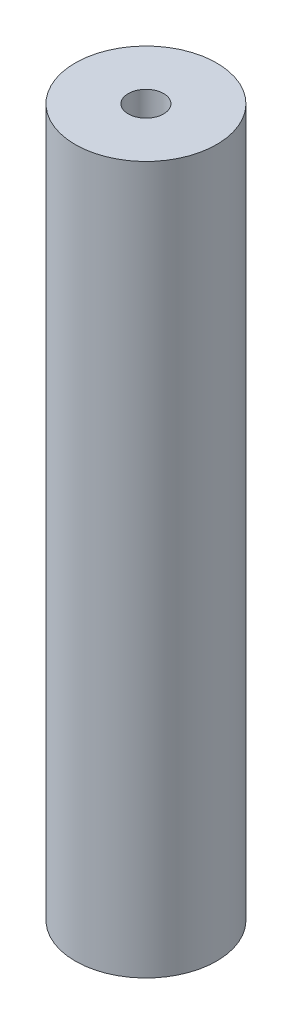
from build123d import *

# Parameters (mm, degrees)
SKETCH1_R           = 100
BOSS_EXTRUDE1_DEPTH = 1000
SKETCH2_R           = 25
CUT_EXTRUDE1_DEPTH  = 50


with BuildPart() as part:
    # Sketch1 → Boss-Extrude1 (new body)
    with BuildSketch(Plane(origin=(0, 0, 0), x_dir=(1, 0, 0), z_dir=(0, 1, 0))):
        Circle(SKETCH1_R)
    extrude(amount=BOSS_EXTRUDE1_DEPTH)

    # Sketch2 → Cut-Extrude1 (cut)
    with BuildSketch(Plane(origin=(0, 1000, 0), x_dir=(1, 0, 0), z_dir=(0, 1, 0))):
        Circle(SKETCH2_R)
    extrude(amount=-CUT_EXTRUDE1_DEPTH, mode=Mode.SUBTRACT)


solid = part.part
